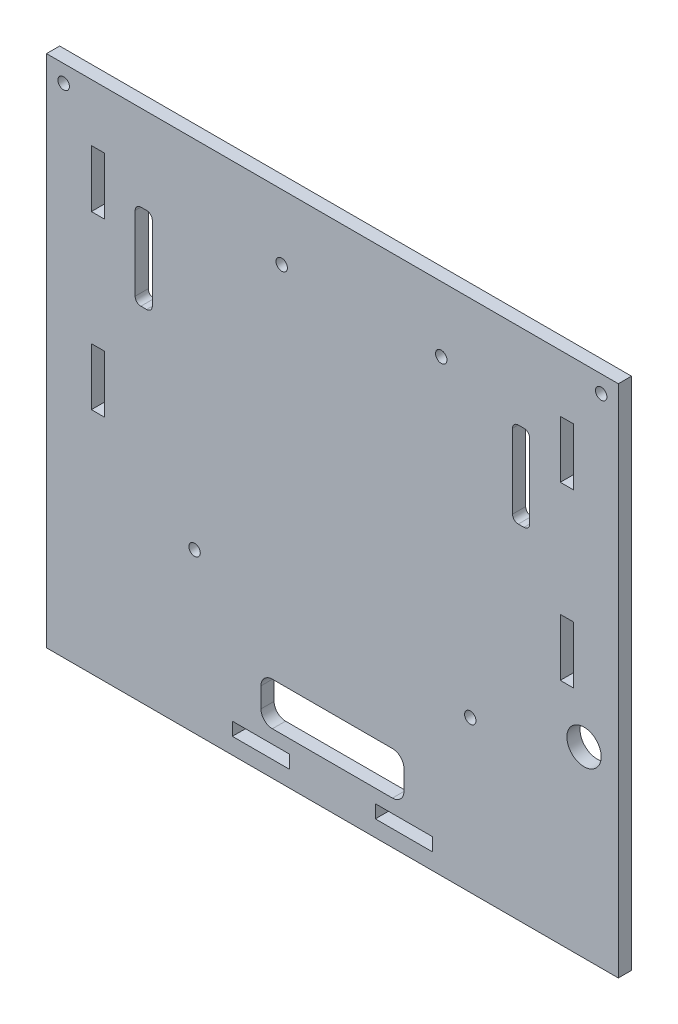
from build123d import *

# Parameters (mm, degrees)
BOSS_EXTRUDE1_DEPTH = 2.3
SKETCH7_W           = 2.3
SKETCH7_H           = 10
SKETCH7_W_2         = 10
SKETCH7_H_2         = 2.3
CUT_EXTRUDE2_DEPTH  = 3.3
SKETCH9_R           = 1
CUT_EXTRUDE4_DEPTH  = 3.3
SKETCH10_W          = 3
SKETCH10_H          = 15
SKETCH10_W_2        = 25
SKETCH10_H_2        = 7.5
CUT_EXTRUDE5_DEPTH  = 3.3
FILLET2_R           = 1
FILLET3_R           = 2
SKETCH11_R          = 3
CUT_EXTRUDE6_DEPTH  = 10


with BuildPart() as part:
    # Sketch1 → Boss-Extrude1 (new body)
    with BuildSketch(Plane.XY):
        Polygon((0, -57), (0, -90), (23, -90), (77, -90), (100, -90), (100, -57), (100, 0), (0, 0), align=None)
    extrude(amount=BOSS_EXTRUDE1_DEPTH)

    # Sketch7 → Cut-Extrude2 (cut, through all)
    with BuildSketch(Plane.XY.offset(2.3)):
        with Locations((91, -15)):
            Rectangle(SKETCH7_W, SKETCH7_H)
        with Locations((91, -45)):
            Rectangle(SKETCH7_W, SKETCH7_H)
        with Locations((9, -15)):
            Rectangle(SKETCH7_W, SKETCH7_H)
        with Locations((9, -45)):
            Rectangle(SKETCH7_W, SKETCH7_H)
        with Locations((37.5, -86)):
            Rectangle(SKETCH7_W_2, SKETCH7_H_2)
        with Locations((62.5, -86)):
            Rectangle(SKETCH7_W_2, SKETCH7_H_2)
    extrude(amount=-CUT_EXTRUDE2_DEPTH, mode=Mode.SUBTRACT)

    # Sketch9 → Cut-Extrude4 (cut, through all)
    with BuildSketch(Plane.XY.offset(2.3)):
        with Locations((3, -3)):
            Circle(SKETCH9_R)
        with Locations((97, -3)):
            Circle(SKETCH9_R)
        with Locations((41.13, -11.4)):
            Circle(SKETCH9_R)
        with Locations((69.03, -11.4)):
            Circle(SKETCH9_R)
        with Locations((25.89, -62.2)):
            Circle(SKETCH9_R)
        with Locations((74.11, -63.5)):
            Circle(SKETCH9_R)
    extrude(amount=-CUT_EXTRUDE4_DEPTH, mode=Mode.SUBTRACT)

    # Sketch10 → Cut-Extrude5 (cut, through all)
    with BuildSketch(Plane.XY.offset(2.3)):
        with Locations((17, -22.5)):
            Rectangle(SKETCH10_W, SKETCH10_H)
        with Locations((83, -22.5)):
            Rectangle(SKETCH10_W, SKETCH10_H)
        with Locations((50, -78.75)):
            Rectangle(SKETCH10_W_2, SKETCH10_H_2)
    extrude(amount=-CUT_EXTRUDE5_DEPTH, mode=Mode.SUBTRACT)

    # Fillet2
    fillet2_edges = [part.edges().sort_by_distance(p)[0] for p in [
        (15.5, -30, 1.15),
        (15.5, -15, 1.15),
        (18.5, -15, 1.15),
        (18.5, -30, 1.15),
        (81.5, -30, 1.15),
        (81.5, -15, 1.15),
        (84.5, -15, 1.15),
        (84.5, -30, 1.15),
    ]]
    fillet(fillet2_edges, radius=FILLET2_R)

    # Fillet3
    fillet3_edges = [part.edges().sort_by_distance(p)[0] for p in [
        (37.5, -82.5, 1.15),
        (37.5, -75, 1.15),
        (62.5, -75, 1.15),
        (62.5, -82.5, 1.15),
    ]]
    fillet(fillet3_edges, radius=FILLET3_R)

    # Sketch11 → Cut-Extrude6 (cut)
    with BuildSketch(Plane.XY.offset(2.3)):
        with Locations((94, -58)):
            Circle(SKETCH11_R)
    extrude(amount=-CUT_EXTRUDE6_DEPTH, mode=Mode.SUBTRACT)


solid = part.part
